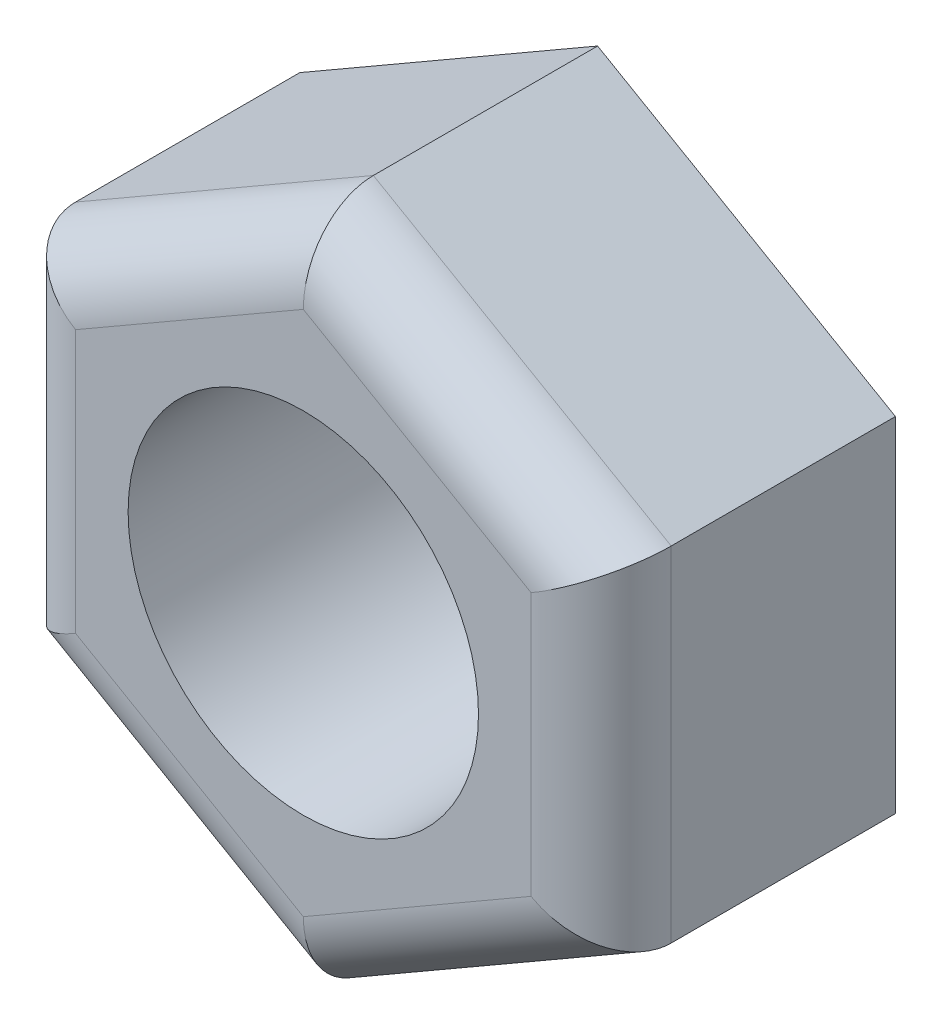
from build123d import *

# Parameters (mm, degrees)
ESQUISSE1_R        = 5
BOSS_EXTRU_1_DEPTH = 8.4
CONG_2_R           = 2


with BuildPart() as part:
    # Esquisse1 → Boss.-Extru.1 (new body)
    with BuildSketch(Plane.XY):
        Polygon((8.5, 4.907477288), (0, 9.814954576), (-8.5, 4.907477288), (-8.5, -4.907477288), (0, -9.814954576), (8.5, -4.907477288), align=None)
        Circle(ESQUISSE1_R, mode=Mode.SUBTRACT)
    extrude(amount=-BOSS_EXTRU_1_DEPTH)

    # Congé2
    cong_2_edges = [part.edges().sort_by_distance(p)[0] for p in [
        (4.25, -7.361215932, 0),
        (-4.25, -7.361215932, 0),
        (-8.5, 0, 0),
        (-4.25, 7.361215932, 0),
        (4.25, 7.361215932, 0),
        (8.5, 0, 0),
    ]]
    fillet(cong_2_edges, radius=CONG_2_R)


solid = part.part
